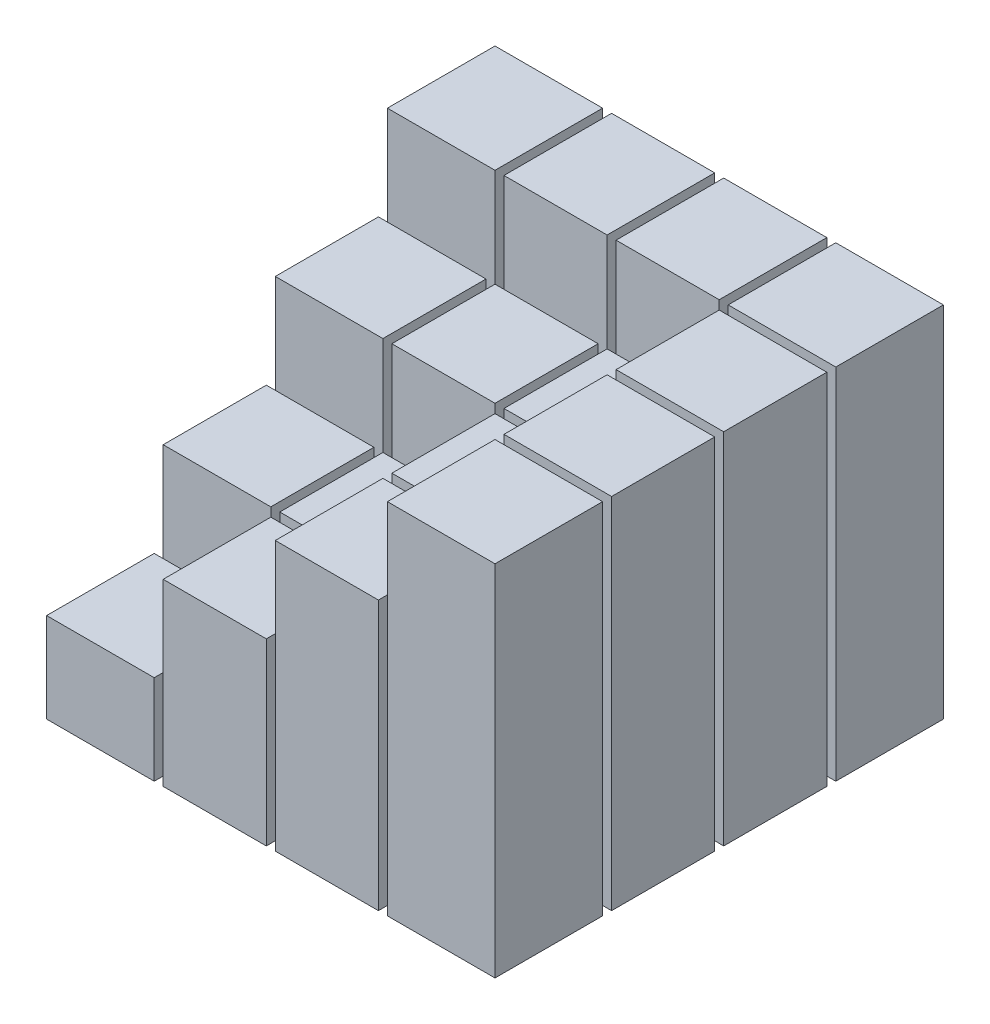
from build123d import *

# Parameters (mm, degrees)
SKETCH1_W           = 25
SKETCH1_H           = 25
BOSS_EXTRUDE1_DEPTH = 5
BOSS_EXTRUDE2_DEPTH = 10
BOSS_EXTRUDE3_DEPTH = 15
BOSS_EXTRUDE4_DEPTH = 20
SKETCH3_W           = 5.75
SKETCH3_H           = 5.75
CUT_EXTRUDE1_DEPTH  = 27.69269563
SKETCH4_R           = 0.8
CUT_EXTRUDE2_DEPTH  = 4


with BuildPart() as part:
    # Sketch1 → Boss-Extrude1 (new body)
    with BuildSketch(Plane(origin=(0, 0, 0), x_dir=(1, 0, 0), z_dir=(0, 1, 0))):
        Rectangle(SKETCH1_W, SKETCH1_H)
    extrude(amount=BOSS_EXTRUDE1_DEPTH)

    # Sketch2 → Boss-Extrude2 (add)
    with BuildSketch(Plane(origin=(0, 0, 0), x_dir=(1, 0, 0), z_dir=(0, 1, 0))):
        Polygon((-12.5, -6.25), (-6.25, -6.25), (-6.25, -12.5), (12.5, -12.5), (12.5, 12.5), (-12.5, 12.5), align=None)
    extrude(amount=BOSS_EXTRUDE2_DEPTH)

    # Sketch2_3 → Boss-Extrude3 (add)
    with BuildSketch(Plane(origin=(0, 0, 0), x_dir=(1, 0, 0), z_dir=(0, 1, 0))):
        Polygon((-12.5, 0), (0, 0), (0, -12.5), (12.5, -12.5), (12.5, 12.5), (-12.5, 12.5), align=None)
    extrude(amount=BOSS_EXTRUDE3_DEPTH)

    # Sketch2_4 → Boss-Extrude4 (add)
    with BuildSketch(Plane(origin=(0, 0, 0), x_dir=(1, 0, 0), z_dir=(0, 1, 0))):
        Polygon((-12.5, 6.25), (6.25, 6.25), (6.25, -12.5), (12.5, -12.5), (12.5, 12.5), (-12.5, 12.5), align=None)
    extrude(amount=BOSS_EXTRUDE4_DEPTH)

    # Sketch3 → Cut-Extrude1 (cut, through all)
    with BuildSketch(Plane(origin=(0, 0, 0), x_dir=(1, 0, 0), z_dir=(0, 1, 0))):
        with BuildLine():
            ThreePointArc((-12.5, 0.25), (-12.75, 0), (-12.5, -0.25))
            Line((-12.5, -0.25), (-6.5, -0.25))
            Line((-6.5, -0.25), (-6.5, -6))
            Line((-6.5, -6), (-12.5, -6))
            ThreePointArc((-12.5, -6), (-12.75, -6.25), (-12.5, -6.5))
            Line((-12.5, -6.5), (-6.5, -6.5))
            Line((-6.5, -6.5), (-6.5, -12.5))
            ThreePointArc((-6.5, -12.5), (-6.25, -12.75), (-6, -12.5))
            Line((-6, -12.5), (-6, -6.5))
            Line((-6, -6.5), (-0.25, -6.5))
            Line((-0.25, -6.5), (-0.25, -12.5))
            ThreePointArc((-0.25, -12.5), (0, -12.75), (0.25, -12.5))
            Line((0.25, -12.5), (0.25, -6.5))
            Line((0.25, -6.5), (6, -6.5))
            Line((6, -6.5), (6, -12.5))
            ThreePointArc((6, -12.5), (6.25, -12.75), (6.5, -12.5))
            Line((6.5, -12.5), (6.5, -6.5))
            Line((6.5, -6.5), (12.5, -6.5))
            ThreePointArc((12.5, -6.5), (12.75, -6.25), (12.5, -6))
            Line((12.5, -6), (6.5, -6))
            Line((6.5, -6), (6.5, -0.25))
            Line((6.5, -0.25), (12.5, -0.25))
            ThreePointArc((12.5, -0.25), (12.75, 0), (12.5, 0.25))
            Line((12.5, 0.25), (6.5, 0.25))
            Line((6.5, 0.25), (6.5, 6))
            Line((6.5, 6), (12.5, 6))
            ThreePointArc((12.5, 6), (12.75, 6.25), (12.5, 6.5))
            Line((12.5, 6.5), (6.5, 6.5))
            Line((6.5, 6.5), (6.5, 12.5))
            ThreePointArc((6.5, 12.5), (6.25, 12.75), (6, 12.5))
            Line((6, 12.5), (6, 6.5))
            Line((6, 6.5), (0.25, 6.5))
            Line((0.25, 6.5), (0.25, 12.5))
            ThreePointArc((0.25, 12.5), (0, 12.75), (-0.25, 12.5))
            Line((-0.25, 12.5), (-0.25, 6.5))
            Line((-0.25, 6.5), (-6, 6.5))
            Line((-6, 6.5), (-6, 12.5))
            ThreePointArc((-6, 12.5), (-6.25, 12.75), (-6.5, 12.5))
            Line((-6.5, 12.5), (-6.5, 6.5))
            Line((-6.5, 6.5), (-12.5, 6.5))
            ThreePointArc((-12.5, 6.5), (-12.75, 6.25), (-12.5, 6))
            Line((-12.5, 6), (-6.5, 6))
            Line((-6.5, 6), (-6.5, 0.25))
            Line((-6.5, 0.25), (-12.5, 0.25))
        make_face()
        with Locations((-3.125, -3.125)):
            Rectangle(SKETCH3_W, SKETCH3_H, mode=Mode.SUBTRACT)
        with Locations((3.125, -3.125)):
            Rectangle(SKETCH3_W, SKETCH3_H, mode=Mode.SUBTRACT)
        with Locations((-3.125, 3.125)):
            Rectangle(SKETCH3_W, SKETCH3_H, mode=Mode.SUBTRACT)
        with Locations((3.125, 3.125)):
            Rectangle(SKETCH3_W, SKETCH3_H, mode=Mode.SUBTRACT)
    extrude(amount=CUT_EXTRUDE1_DEPTH, mode=Mode.SUBTRACT)


with BuildPart() as cut_extrude1_piece_1:
    # of the separate pieces the step leaves, piece 1, a body of its own (cut_extrude1_pieces)
    add(part.part.solids().sort_by_distance((-12.5, 0, -6.5))[0])


with BuildPart() as cut_extrude1_piece_2:
    # of the separate pieces the step leaves, piece 2, a body of its own (cut_extrude1_pieces)
    add(part.part.solids().sort_by_distance((6.5, 0, -6.5))[0])


with BuildPart() as cut_extrude1_piece_3:
    # of the separate pieces the step leaves, piece 3, a body of its own (cut_extrude1_pieces)
    add(part.part.solids().sort_by_distance((6.5, 0, 12.5))[0])


with BuildPart() as cut_extrude1_piece_4:
    # of the separate pieces the step leaves, piece 4, a body of its own (cut_extrude1_pieces)
    add(part.part.solids().sort_by_distance((0.25, 0, -6.5))[0])


with BuildPart() as cut_extrude1_piece_5:
    # of the separate pieces the step leaves, piece 5, a body of its own (cut_extrude1_pieces)
    add(part.part.solids().sort_by_distance((-6, 0, -6.5))[0])


with BuildPart() as cut_extrude1_piece_6:
    # of the separate pieces the step leaves, piece 6, a body of its own (cut_extrude1_pieces)
    add(part.part.solids().sort_by_distance((6.5, 0, 0.25))[0])


with BuildPart() as cut_extrude1_piece_7:
    # of the separate pieces the step leaves, piece 7, a body of its own (cut_extrude1_pieces)
    add(part.part.solids().sort_by_distance((6.5, 0, -6))[0])


with BuildPart() as cut_extrude1_piece_8:
    # of the separate pieces the step leaves, piece 8, a body of its own (cut_extrude1_pieces)
    add(part.part.solids().sort_by_distance((0.25, 0, 12.5))[0])


with BuildPart() as cut_extrude1_piece_9:
    # of the separate pieces the step leaves, piece 9, a body of its own (cut_extrude1_pieces)
    add(part.part.solids().sort_by_distance((-12.5, 0, -0.25))[0])


with BuildPart() as cut_extrude1_piece_10:
    # of the separate pieces the step leaves, piece 10, a body of its own (cut_extrude1_pieces)
    add(part.part.solids().sort_by_distance((6, 0, 6))[0])


with BuildPart() as cut_extrude1_piece_11:
    # of the separate pieces the step leaves, piece 11, a body of its own (cut_extrude1_pieces)
    add(part.part.solids().sort_by_distance((6, 0, -0.25))[0])


with BuildPart() as cut_extrude1_piece_12:
    # of the separate pieces the step leaves, piece 12, a body of its own (cut_extrude1_pieces)
    add(part.part.solids().sort_by_distance((-0.25, 0, -0.25))[0])


with BuildPart() as cut_extrude1_piece_13:
    # of the separate pieces the step leaves, piece 13, a body of its own (cut_extrude1_pieces)
    add(part.part.solids().sort_by_distance((-12.5, 0, 6))[0])


with BuildPart() as cut_extrude1_piece_14:
    # of the separate pieces the step leaves, piece 14, a body of its own (cut_extrude1_pieces)
    add(part.part.solids().sort_by_distance((-6, 0, 12.5))[0])


with BuildPart() as cut_extrude1_piece_15:
    # of the separate pieces the step leaves, piece 15, a body of its own (cut_extrude1_pieces)
    add(part.part.solids().sort_by_distance((-0.25, 0, 6))[0])


with BuildPart() as cut_extrude1_piece_16:
    # of the separate pieces the step leaves, piece 16, a body of its own (cut_extrude1_pieces)
    add(part.part.solids().sort_by_distance((-12.5, 0, 12.5))[0])


with BuildPart() as cut_extrude2_tool:
    # Sketch4 → Cut-Extrude2 (new body)
    with BuildSketch(Plane(origin=(0, 0, 0), x_dir=(1, 0, 0), z_dir=(0, 1, 0))):
        with Locations((-9.5, -9.5)):
            Circle(SKETCH4_R)
        with Locations((-3.25, -9.5)):
            Circle(SKETCH4_R)
        with Locations((3, -9.5)):
            Circle(SKETCH4_R)
        with Locations((9.25, -9.5)):
            Circle(SKETCH4_R)
        with Locations((-3.25, -3.25)):
            Circle(SKETCH4_R)
        with Locations((3, -3.25)):
            Circle(SKETCH4_R)
        with Locations((9.25, -3.25)):
            Circle(SKETCH4_R)
        with Locations((-3.25, 3)):
            Circle(SKETCH4_R)
        with Locations((3, 3)):
            Circle(SKETCH4_R)
        with Locations((9.25, 3)):
            Circle(SKETCH4_R)
        with Locations((-3.25, 9.25)):
            Circle(SKETCH4_R)
        with Locations((3, 9.25)):
            Circle(SKETCH4_R)
        with Locations((9.25, 9.25)):
            Circle(SKETCH4_R)
        with Locations((-9.5, -3.25)):
            Circle(SKETCH4_R)
        with Locations((-9.5, 3)):
            Circle(SKETCH4_R)
        with Locations((-9.5, 9.25)):
            Circle(SKETCH4_R)
    extrude(amount=CUT_EXTRUDE2_DEPTH)


with BuildPart() as cut_extrude1_piece_1_1:
    add(cut_extrude1_piece_1.part)

    # Cut-Extrude2: cut by cut_extrude2_tool
    add(cut_extrude2_tool.part, mode=Mode.SUBTRACT)


with BuildPart() as cut_extrude1_piece_2_1:
    add(cut_extrude1_piece_2.part)

    # Cut-Extrude2: cut by cut_extrude2_tool
    add(cut_extrude2_tool.part, mode=Mode.SUBTRACT)


with BuildPart() as cut_extrude1_piece_3_1:
    add(cut_extrude1_piece_3.part)

    # Cut-Extrude2: cut by cut_extrude2_tool
    add(cut_extrude2_tool.part, mode=Mode.SUBTRACT)


with BuildPart() as cut_extrude1_piece_4_1:
    add(cut_extrude1_piece_4.part)

    # Cut-Extrude2: cut by cut_extrude2_tool
    add(cut_extrude2_tool.part, mode=Mode.SUBTRACT)


with BuildPart() as cut_extrude1_piece_5_1:
    add(cut_extrude1_piece_5.part)

    # Cut-Extrude2: cut by cut_extrude2_tool
    add(cut_extrude2_tool.part, mode=Mode.SUBTRACT)


with BuildPart() as cut_extrude1_piece_6_1:
    add(cut_extrude1_piece_6.part)

    # Cut-Extrude2: cut by cut_extrude2_tool
    add(cut_extrude2_tool.part, mode=Mode.SUBTRACT)


with BuildPart() as cut_extrude1_piece_7_1:
    add(cut_extrude1_piece_7.part)

    # Cut-Extrude2: cut by cut_extrude2_tool
    add(cut_extrude2_tool.part, mode=Mode.SUBTRACT)


with BuildPart() as cut_extrude1_piece_8_1:
    add(cut_extrude1_piece_8.part)

    # Cut-Extrude2: cut by cut_extrude2_tool
    add(cut_extrude2_tool.part, mode=Mode.SUBTRACT)


with BuildPart() as cut_extrude1_piece_9_1:
    add(cut_extrude1_piece_9.part)

    # Cut-Extrude2: cut by cut_extrude2_tool
    add(cut_extrude2_tool.part, mode=Mode.SUBTRACT)


with BuildPart() as cut_extrude1_piece_10_1:
    add(cut_extrude1_piece_10.part)

    # Cut-Extrude2: cut by cut_extrude2_tool
    add(cut_extrude2_tool.part, mode=Mode.SUBTRACT)


with BuildPart() as cut_extrude1_piece_11_1:
    add(cut_extrude1_piece_11.part)

    # Cut-Extrude2: cut by cut_extrude2_tool
    add(cut_extrude2_tool.part, mode=Mode.SUBTRACT)


with BuildPart() as cut_extrude1_piece_12_1:
    add(cut_extrude1_piece_12.part)

    # Cut-Extrude2: cut by cut_extrude2_tool
    add(cut_extrude2_tool.part, mode=Mode.SUBTRACT)


with BuildPart() as cut_extrude1_piece_13_1:
    add(cut_extrude1_piece_13.part)

    # Cut-Extrude2: cut by cut_extrude2_tool
    add(cut_extrude2_tool.part, mode=Mode.SUBTRACT)


with BuildPart() as cut_extrude1_piece_14_1:
    add(cut_extrude1_piece_14.part)

    # Cut-Extrude2: cut by cut_extrude2_tool
    add(cut_extrude2_tool.part, mode=Mode.SUBTRACT)


with BuildPart() as cut_extrude1_piece_15_1:
    add(cut_extrude1_piece_15.part)

    # Cut-Extrude2: cut by cut_extrude2_tool
    add(cut_extrude2_tool.part, mode=Mode.SUBTRACT)


with BuildPart() as cut_extrude1_piece_16_1:
    add(cut_extrude1_piece_16.part)

    # Cut-Extrude2: cut by cut_extrude2_tool
    add(cut_extrude2_tool.part, mode=Mode.SUBTRACT)


solid = Compound([cut_extrude1_piece_1_1.part, cut_extrude1_piece_2_1.part, cut_extrude1_piece_3_1.part, cut_extrude1_piece_4_1.part, cut_extrude1_piece_5_1.part, cut_extrude1_piece_6_1.part, cut_extrude1_piece_7_1.part, cut_extrude1_piece_8_1.part, cut_extrude1_piece_9_1.part, cut_extrude1_piece_10_1.part, cut_extrude1_piece_11_1.part, cut_extrude1_piece_12_1.part, cut_extrude1_piece_13_1.part, cut_extrude1_piece_14_1.part, cut_extrude1_piece_15_1.part, cut_extrude1_piece_16_1.part])
